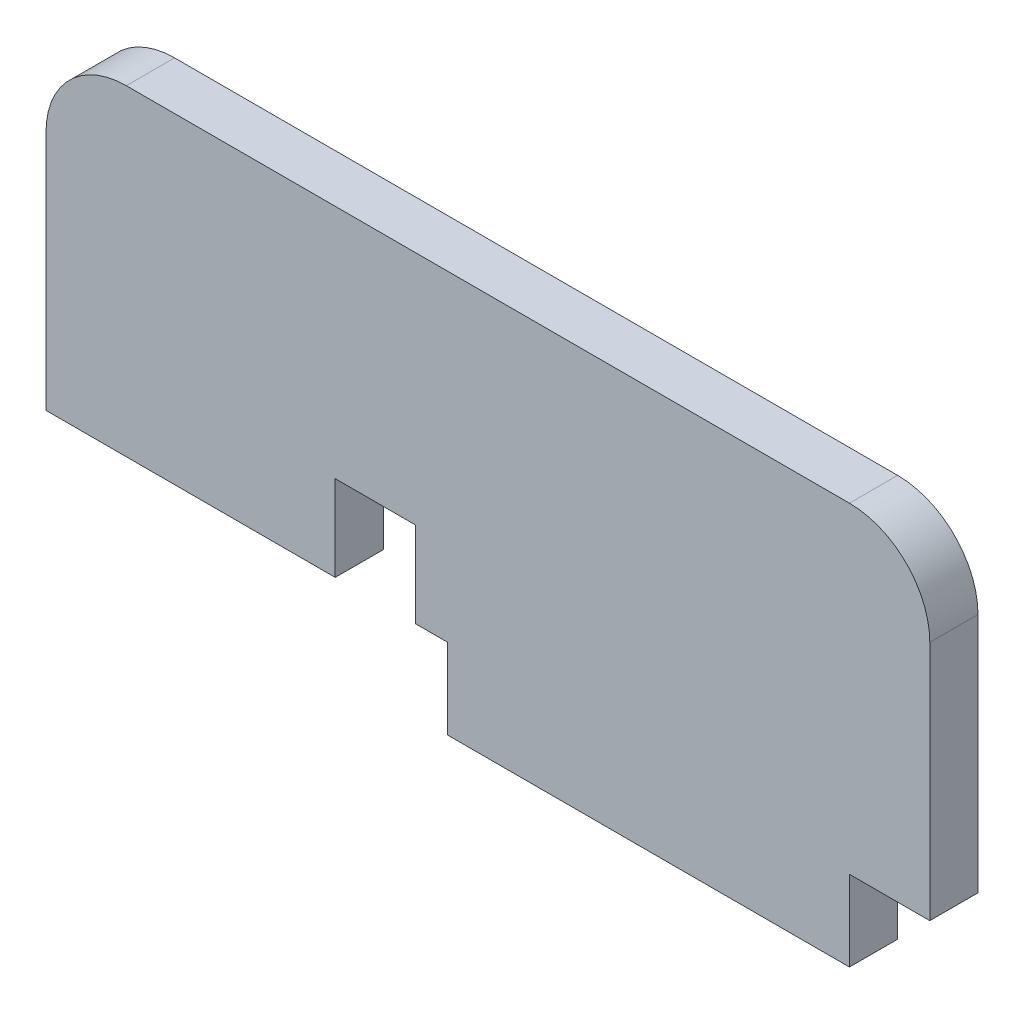
from build123d import *

# Parameters (mm, degrees)
RESSALTO_EXTRUS_O1_DEPTH = 3
ESBO_O3_W                = 5
ESBO_O3_H                = 5.322149945
CORTE_EXTRUS_O2_DEPTH    = 4


with BuildPart() as part:
    # Esboço1 → Ressalto-extrusão1 (new body)
    with BuildSketch(Plane.XY):
        with BuildLine():
            Line((-7.94118013, 1.369756817), (-2.94118013, 1.369756817))
            Line((-2.94118013, 1.369756817), (-2.94118013, 16.369756817))
            ThreePointArc((-2.94118013, 16.369756817), (-4.405646224, 19.905290723), (-7.94118013, 21.369756817))
            Line((-7.94118013, 21.369756817), (-52.94118013, 21.369756817))
            ThreePointArc((-52.94118013, 21.369756817), (-56.476714036, 19.905290723), (-57.94118013, 16.369756817))
            Line((-57.94118013, 16.369756817), (-57.94118013, 1.369756817))
            Line((-57.94118013, 1.369756817), (-32.94118013, 1.369756817))
            Line((-32.94118013, 1.369756817), (-32.94118013, -3.630243183))
            Line((-32.94118013, -3.630243183), (-7.94118013, -3.630243183))
            Line((-7.94118013, -3.630243183), (-7.94118013, 1.369756817))
        make_face()
    extrude(amount=RESSALTO_EXTRUS_O1_DEPTH)

    # Esboço3 → Corte-extrusão2 (cut, through all)
    with BuildSketch(Plane.XY.offset(3)):
        with Locations((-37.44118013, 4.03083179)):
            Rectangle(ESBO_O3_W, ESBO_O3_H)
    extrude(amount=-CORTE_EXTRUS_O2_DEPTH, mode=Mode.SUBTRACT)


solid = part.part
